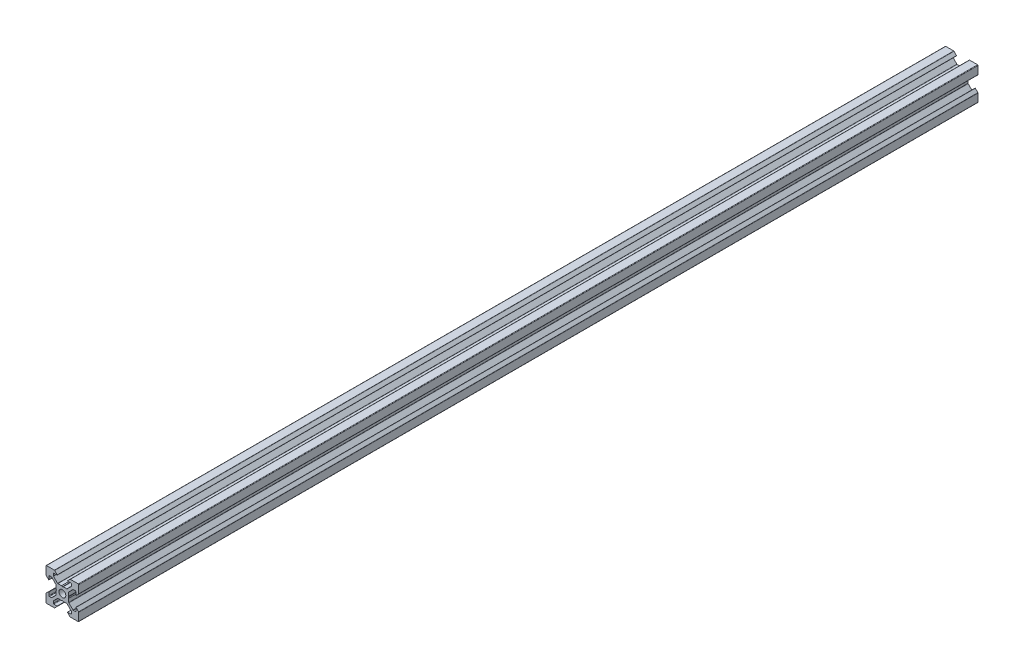
from build123d import *

# Parameters (mm, degrees)
BOSS_EXTRU_1_DEPTH = 550


with BuildPart() as part:
    # Esquisse1 → Boss.-Extru.1 (new body)
    with BuildSketch(Plane.XY):
        with BuildLine():
            Line((18.774857412, -2.895228684), (18.774857412, -4.894568513))
            ThreePointArc((18.774857412, -4.894568513), (18.686989447, -5.106700547), (18.474857412, -5.194568513))
            Line((18.474857412, -5.194568513), (17.259121481, -5.194568513))
            ThreePointArc((17.259121481, -5.194568513), (17.144316451, -5.171732372), (17.046989447, -5.106700547))
            Line((17.046989447, -5.106700547), (14.56338555, -2.62309665))
            ThreePointArc((14.56338555, -2.62309665), (14.498353724, -2.525769645), (14.475517584, -2.410964616))
            Line((14.475517584, -2.410964616), (14.475517584, -0.214843927))
            Line((14.475517584, -0.214843927), (14.175517584, 0.304771316))
            Line((14.175517584, 0.304771316), (14.475517584, 0.824386558))
            Line((14.475517584, 0.824386558), (14.475517584, 3.020507247))
            ThreePointArc((14.475517584, 3.020507247), (14.498353724, 3.135312277), (14.56338555, 3.232639281))
            Line((14.56338555, 3.232639281), (17.046989447, 5.716243178))
            ThreePointArc((17.046989447, 5.716243178), (17.144316451, 5.781275004), (17.259121481, 5.804111144))
            Line((17.259121481, 5.804111144), (18.474857412, 5.804111144))
            ThreePointArc((18.474857412, 5.804111144), (18.686989447, 5.716243178), (18.774857412, 5.504111144))
            Line((18.774857412, 5.504111144), (18.774857412, 3.504771316))
            ThreePointArc((18.774857412, 3.504771316), (18.836589069, 3.412383362), (18.94556809, 3.434060638))
            Line((18.94556809, 3.434060638), (20.486989447, 4.975481994))
            ThreePointArc((20.486989447, 4.975481994), (20.552021272, 5.072808998), (20.574857412, 5.187614028))
            Line((20.574857412, 5.187614028), (20.574857412, 10.004771316))
            ThreePointArc((20.574857412, 10.004771316), (20.486989447, 10.21690335), (20.274857412, 10.304771316))
            Line((20.274857412, 10.304771316), (15.457700125, 10.304771316))
            ThreePointArc((15.457700125, 10.304771316), (15.342895095, 10.281935175), (15.24556809, 10.21690335))
            Line((15.24556809, 10.21690335), (13.704146734, 8.675481994))
            ThreePointArc((13.704146734, 8.675481994), (13.682469459, 8.566502972), (13.774857412, 8.504771316))
            Line((13.774857412, 8.504771316), (15.77419724, 8.504771316))
            ThreePointArc((15.77419724, 8.504771316), (15.986329275, 8.41690335), (16.07419724, 8.204771316))
            Line((16.07419724, 8.204771316), (16.07419724, 6.989035384))
            ThreePointArc((16.07419724, 6.989035384), (16.0513611, 6.874230355), (15.986329275, 6.77690335))
            Line((15.986329275, 6.77690335), (13.502725378, 4.293299453))
            ThreePointArc((13.502725378, 4.293299453), (13.405398373, 4.228267628), (13.290593344, 4.205431487))
            Line((13.290593344, 4.205431487), (11.094472654, 4.205431487))
            Line((11.094472654, 4.205431487), (10.574857412, 3.905431487))
            Line((10.574857412, 3.905431487), (10.05524217, 4.205431487))
            Line((10.05524217, 4.205431487), (7.859121481, 4.205431487))
            ThreePointArc((7.859121481, 4.205431487), (7.744316451, 4.228267628), (7.646989447, 4.293299453))
            Line((7.646989447, 4.293299453), (5.16338555, 6.77690335))
            ThreePointArc((5.16338555, 6.77690335), (5.098353724, 6.874230355), (5.075517584, 6.989035384))
            Line((5.075517584, 6.989035384), (5.075517584, 8.204771316))
            ThreePointArc((5.075517584, 8.204771316), (5.16338555, 8.41690335), (5.375517584, 8.504771316))
            Line((5.375517584, 8.504771316), (7.374857412, 8.504771316))
            ThreePointArc((7.374857412, 8.504771316), (7.467245365, 8.566502972), (7.44556809, 8.675481994))
            Line((7.44556809, 8.675481994), (5.904146734, 10.21690335))
            ThreePointArc((5.904146734, 10.21690335), (5.806819729, 10.281935175), (5.6920147, 10.304771316))
            Line((5.6920147, 10.304771316), (0.874857412, 10.304771316))
            ThreePointArc((0.874857412, 10.304771316), (0.662725378, 10.21690335), (0.574857412, 10.004771316))
            Line((0.574857412, 10.004771316), (0.574857412, 5.187614028))
            ThreePointArc((0.574857412, 5.187614028), (0.597693552, 5.072808998), (0.662725378, 4.975481994))
            Line((0.662725378, 4.975481994), (2.204146734, 3.434060638))
            ThreePointArc((2.204146734, 3.434060638), (2.313125755, 3.412383362), (2.374857412, 3.504771316))
            Line((2.374857412, 3.504771316), (2.374857412, 5.504111144))
            ThreePointArc((2.374857412, 5.504111144), (2.462725378, 5.716243178), (2.674857412, 5.804111144))
            Line((2.674857412, 5.804111144), (3.890593344, 5.804111144))
            ThreePointArc((3.890593344, 5.804111144), (4.005398373, 5.781275004), (4.102725378, 5.716243178))
            Line((4.102725378, 5.716243178), (6.586329275, 3.232639281))
            ThreePointArc((6.586329275, 3.232639281), (6.6513611, 3.135312277), (6.67419724, 3.020507247))
            Line((6.67419724, 3.020507247), (6.67419724, 0.824386558))
            Line((6.67419724, 0.824386558), (6.97419724, 0.304771316))
            Line((6.97419724, 0.304771316), (6.67419724, -0.214843927))
            Line((6.67419724, -0.214843927), (6.67419724, -2.410964616))
            ThreePointArc((6.67419724, -2.410964616), (6.6513611, -2.525769645), (6.586329275, -2.62309665))
            Line((6.586329275, -2.62309665), (4.102725378, -5.106700547))
            ThreePointArc((4.102725378, -5.106700547), (4.005398373, -5.171732372), (3.890593344, -5.194568513))
            Line((3.890593344, -5.194568513), (2.674857412, -5.194568513))
            ThreePointArc((2.674857412, -5.194568513), (2.462725378, -5.106700547), (2.374857412, -4.894568513))
            Line((2.374857412, -4.894568513), (2.374857412, -2.895228684))
            ThreePointArc((2.374857412, -2.895228684), (2.313125755, -2.802840731), (2.204146734, -2.824518006))
            Line((2.204146734, -2.824518006), (0.662725378, -4.365939362))
            ThreePointArc((0.662725378, -4.365939362), (0.597693552, -4.463266367), (0.574857412, -4.578071397))
            Line((0.574857412, -4.578071397), (0.574857412, -9.395228684))
            ThreePointArc((0.574857412, -9.395228684), (0.662725378, -9.607360719), (0.874857412, -9.695228684))
            Line((0.874857412, -9.695228684), (5.6920147, -9.695228684))
            ThreePointArc((5.6920147, -9.695228684), (5.806819729, -9.672392544), (5.904146734, -9.607360719))
            Line((5.904146734, -9.607360719), (7.44556809, -8.065939362))
            ThreePointArc((7.44556809, -8.065939362), (7.467245365, -7.956960341), (7.374857412, -7.895228684))
            Line((7.374857412, -7.895228684), (5.375517584, -7.895228684))
            ThreePointArc((5.375517584, -7.895228684), (5.16338555, -7.807360719), (5.075517584, -7.595228684))
            Line((5.075517584, -7.595228684), (5.075517584, -6.379492753))
            ThreePointArc((5.075517584, -6.379492753), (5.098353724, -6.264687723), (5.16338555, -6.167360719))
            Line((5.16338555, -6.167360719), (7.646989447, -3.683756822))
            ThreePointArc((7.646989447, -3.683756822), (7.744316451, -3.618724996), (7.859121481, -3.595888856))
            Line((7.859121481, -3.595888856), (10.05524217, -3.595888856))
            Line((10.05524217, -3.595888856), (10.574857412, -3.295888856))
            Line((10.574857412, -3.295888856), (11.094472654, -3.595888856))
            Line((11.094472654, -3.595888856), (13.290593344, -3.595888856))
            ThreePointArc((13.290593344, -3.595888856), (13.405398373, -3.618724996), (13.502725378, -3.683756822))
            Line((13.502725378, -3.683756822), (15.986329275, -6.167360719))
            ThreePointArc((15.986329275, -6.167360719), (16.0513611, -6.264687723), (16.07419724, -6.379492753))
            Line((16.07419724, -6.379492753), (16.07419724, -7.595228684))
            ThreePointArc((16.07419724, -7.595228684), (15.986329275, -7.807360719), (15.77419724, -7.895228684))
            Line((15.77419724, -7.895228684), (13.774857412, -7.895228684))
            ThreePointArc((13.774857412, -7.895228684), (13.682469459, -7.956960341), (13.704146734, -8.065939362))
            Line((13.704146734, -8.065939362), (15.24556809, -9.607360719))
            ThreePointArc((15.24556809, -9.607360719), (15.342895095, -9.672392544), (15.457700125, -9.695228684))
            Line((15.457700125, -9.695228684), (20.274857412, -9.695228684))
            ThreePointArc((20.274857412, -9.695228684), (20.486989447, -9.607360719), (20.574857412, -9.395228684))
            Line((20.574857412, -9.395228684), (20.574857412, -4.578071397))
            ThreePointArc((20.574857412, -4.578071397), (20.552021272, -4.463266367), (20.486989447, -4.365939362))
            Line((20.486989447, -4.365939362), (18.94556809, -2.824518006))
            ThreePointArc((18.94556809, -2.824518006), (18.836589069, -2.802840731), (18.774857412, -2.895228684))
        make_face()
        with BuildLine():
            ThreePointArc((10.574857412, -1.795228684), (12.059781653, -1.180152925), (12.674857412, 0.304771316))
            ThreePointArc((12.674857412, 0.304771316), (12.059781653, 1.789695556), (10.574857412, 2.404771316))
            ThreePointArc((10.574857412, 2.404771316), (9.089933172, 1.789695556), (8.474857412, 0.304771316))
            ThreePointArc((8.474857412, 0.304771316), (9.089933172, -1.180152925), (10.574857412, -1.795228684))
        make_face(mode=Mode.SUBTRACT)
    extrude(amount=BOSS_EXTRU_1_DEPTH)


solid = part.part
